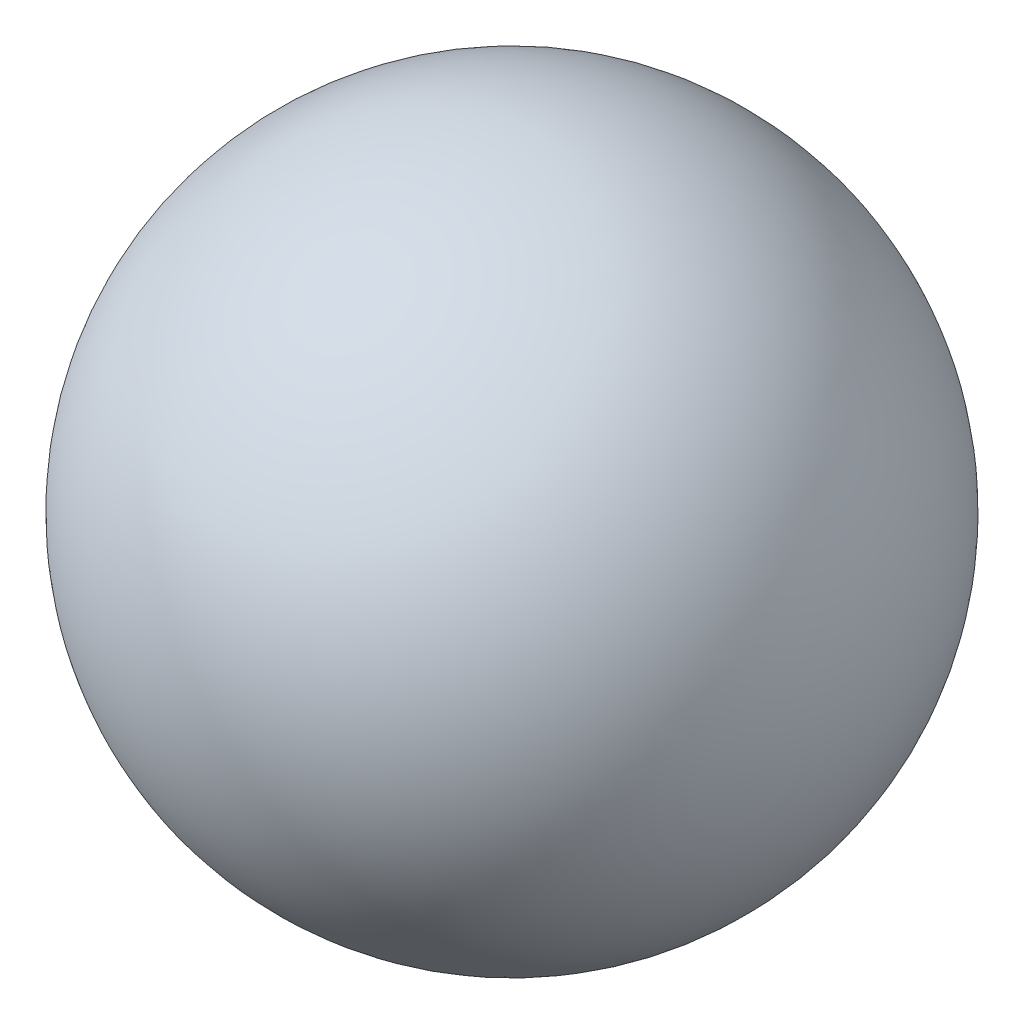
from build123d import *


with BuildPart() as part:
    # 草圖1 → 旋轉1 (revolve)
    with BuildSketch(Plane(origin=(0, 0, 0), x_dir=(1, 0, 0), z_dir=(0, 1, 0))):
        with BuildLine():
            Line((0, 16), (0, -16))
            ThreePointArc((0, -16), (16, 0), (0, 16))
        make_face()
    revolve(axis=Axis((0, 0, -2.410765407), (0, 0, 1)))


solid = part.part
